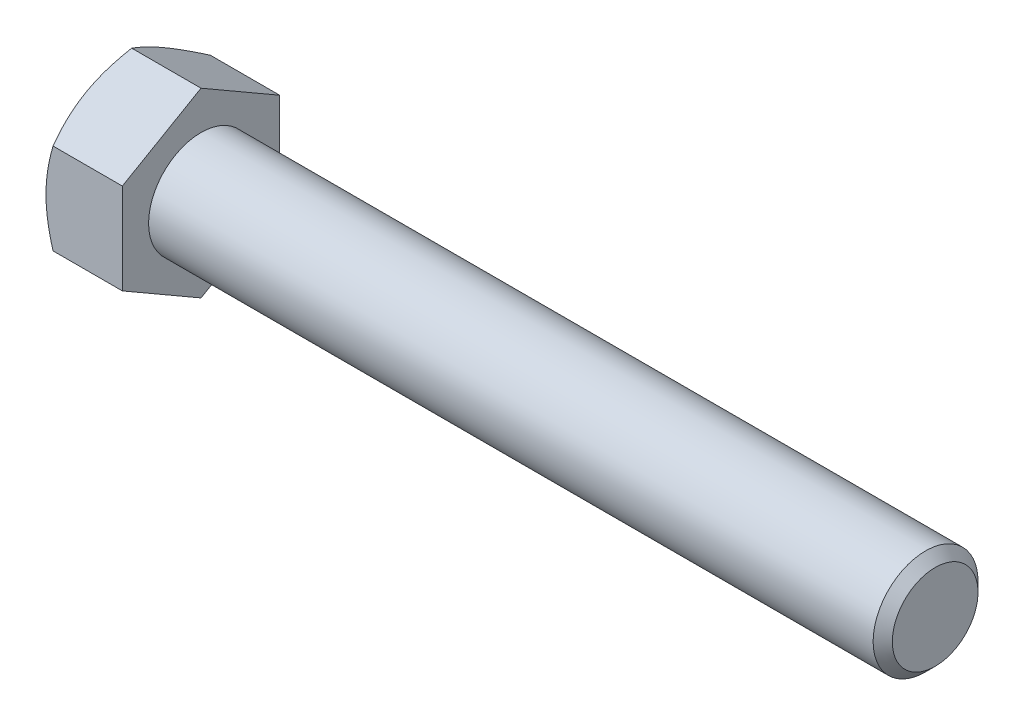
from build123d import *

# Parameters (mm, degrees)
BASEHEAD_DEPTH = 9.2456


with BuildPart() as part:
    # Sketch1 → BaseHead (new body)
    with BuildSketch(Plane(origin=(0, 0, 0), x_dir=(0, 0, -1), z_dir=(1, 0, 0))):
        Polygon((9.525, 5.499261314), (9.525, -5.499261314), (0, -10.998522628), (-9.525, -5.499261314), (-9.525, 5.499261314), (0, 10.998522628), align=None)
    extrude(amount=BASEHEAD_DEPTH)

    # BodySke → BaseBody (revolve)
    with BuildSketch(Plane.XY, mode=Mode.PRIVATE) as basebody_sk:
        Polygon((0, 0), (98.1456, 0), (98.1456, 5.18668), (96.98228, 6.35), (0, 6.35), align=None)
    revolve(basebody_sk.sketch.rotate(Axis((0, 0, 0), (1, 0, 0)), 90), axis=Axis((0, 0, 0), (1, 0, 0)))  # turned: the seam where the file's is

    # Sketch3 → HeadChamfer (revolve, cut)
    with BuildSketch(Plane.XY, mode=Mode.PRIVATE) as headchamfer_sk:
        Polygon((0, 9.525), (4.516912895, 17.348522628), (4.516912895, 23.698522628), (-12.7, 23.698522628), (-12.7, 9.525), align=None)
    revolve(headchamfer_sk.sketch.rotate(Axis((0, 0, 0), (1, 0, 0)), 90), axis=Axis((0, 0, 0), (1, 0, 0)), mode=Mode.SUBTRACT)  # turned: the seam where the file's is


solid = part.part
